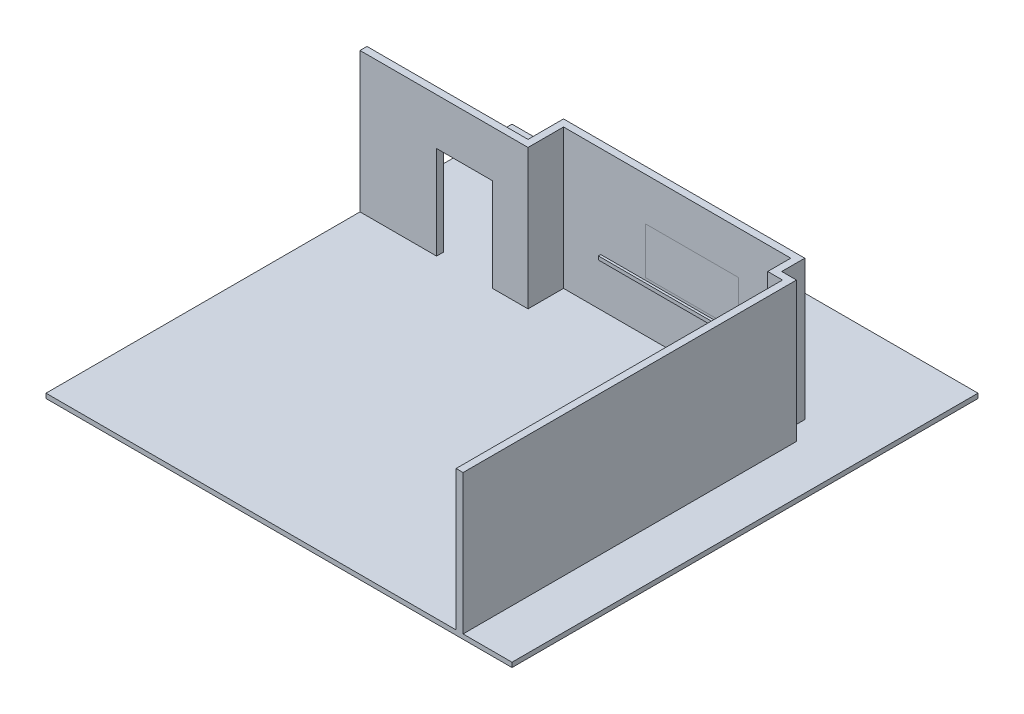
from build123d import *

# Parameters (mm, degrees)
SKETCH1_W               = 10000
SKETCH1_H               = 10000
BOSS_EXTRUDE1_DEPTH     = 100
BOSS_EXTRUDE2_DEPTH     = 3000
SKETCH4_W               = 2000
SKETCH4_H               = 1000
SKETCH4_W_2             = 1200
SKETCH4_H_2             = 2000
CUT_EXTRUDE1_DEPTH      = 7501
CUT_EXTRUDE1_DEPTH_BACK = 2501
SKETCH4_2_W             = 2000
SKETCH4_2_H             = 1000
BOSS_EXTRUDE3_DEPTH     = 150
SKETCH5_W               = 558.8
SKETCH5_H               = 924.56
BOSS_EXTRUDE4_DEPTH     = 1900
SKETCH6_W               = 4076.8
SKETCH6_H               = 76.2
BOSS_EXTRUDE5_DEPTH     = 50.8


with BuildPart() as part:
    # Sketch1 → Boss-Extrude1 (new body)
    with BuildSketch(Plane(origin=(0, 0, 0), x_dir=(1, 0, 0), z_dir=(0, 1, 0))):
        Rectangle(SKETCH1_W, SKETCH1_H)
    extrude(amount=-BOSS_EXTRUDE1_DEPTH)

    # Sketch3 → Boss-Extrude2 (add)
    with BuildSketch(Plane(origin=(0, 0, 0), x_dir=(1, 0, 0), z_dir=(0, 1, 0))):
        Polygon((3482.5, 2500), (-1394.3, 2500), (-1394.3, 1738), (-5000, 1738), (-5000, 1888), (-1544.3, 1888), (-1544.3, 2650), (3632.5, 2650), (3632.5, 2155), (3950, 2155), (3950, -5000), (3800, -5000), (3800, 2005), (3482.5, 2005), align=None)
    extrude(amount=BOSS_EXTRUDE2_DEPTH)

    # Sketch4 → Cut-Extrude1 (cut, two sides)
    with BuildSketch(Plane.XY.offset(-2500)) as cut_extrude1_sk:
        with Locations((1364.9, 1579.5)):
            Rectangle(SKETCH4_W, SKETCH4_H)
        with Locations((-2756.3, 1000)):
            Rectangle(SKETCH4_W_2, SKETCH4_H_2)
    extrude(amount=CUT_EXTRUDE1_DEPTH, mode=Mode.SUBTRACT)
    extrude(cut_extrude1_sk.sketch, amount=-CUT_EXTRUDE1_DEPTH_BACK, mode=Mode.SUBTRACT)


with BuildPart() as body_2:
    # Sketch4_2 → Boss-Extrude3 (new body)
    with BuildSketch(Plane.XY.offset(-2500)):
        with Locations((1364.9, 1579.5)):
            Rectangle(SKETCH4_2_W, SKETCH4_2_H)
    extrude(amount=-BOSS_EXTRUDE3_DEPTH)


with BuildPart() as body_3:
    # Sketch5 → Boss-Extrude4 (new body)
    with BuildSketch(Plane(origin=(0, 0, 0), x_dir=(1, 0, 0), z_dir=(0, 1, 0))):
        with Locations((3520.6, 425.12)):
            Rectangle(SKETCH5_W, SKETCH5_H)
    extrude(amount=BOSS_EXTRUDE4_DEPTH)


with BuildPart() as body_4:
    # Sketch6 → Boss-Extrude5 (new body)
    with BuildSketch(Plane.XY.offset(-2500)):
        with Locations((1444.1, 990.6)):
            Rectangle(SKETCH6_W, SKETCH6_H)
    extrude(amount=BOSS_EXTRUDE5_DEPTH)


solid = Compound([part.part, body_2.part, body_3.part, body_4.part])
